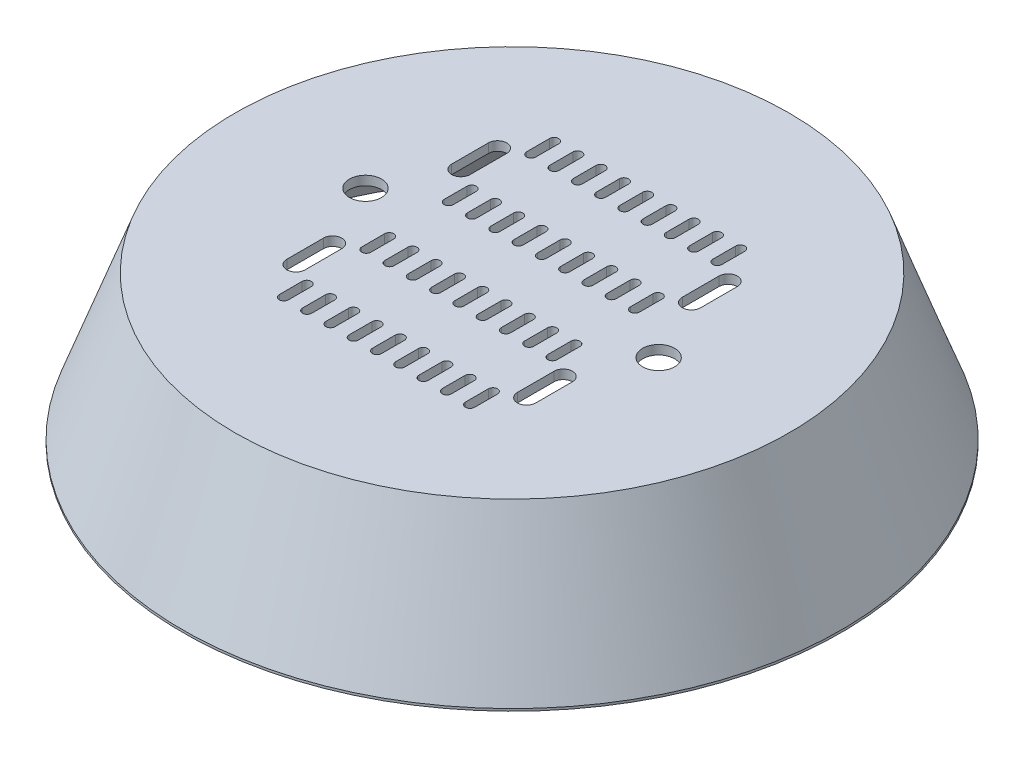
from build123d import *

# Parameters (mm, degrees)
CORTAR_EXTRUIR1_REACH   = 34
CROQUIS3_R              = 3.5
CORTAR_EXTRUIR2_DEPTH   = 2
CROQUIS5_R              = 7.5
CROQUIS5_R_2            = 3.5
SALIENTE_EXTRUIR1_DEPTH = 2
CORTAR_EXTRUIR3_REACH   = 34


with BuildPart() as part:
    # Croquis1 → Revolución1 (revolve)
    with BuildSketch(Plane.XY):
        Polygon((0, 0), (40, 0), (59.080892972, 0), (70, -30), (71.946370428, -30), (71.946370428, -29.5), (60.481308048, 2), (40, 2), (0, 2), align=None)
    revolve(axis=Axis((0, 0, 0), (0, 1, 0)))

    # Croquis3 → Cortar-Extruir1 (cut, up to next)
    with BuildSketch(Plane(origin=(0, 2, 0), x_dir=(1, 0, 0), z_dir=(0, 1, 0)), mode=Mode.PRIVATE) as cortar_extruir1_sk1:
        with Locations((-32, 0)):
            Circle(CROQUIS3_R)
    cortar_extruir1_tool1 = extrude(cortar_extruir1_sk1.sketch, amount=-CORTAR_EXTRUIR1_REACH, mode=Mode.PRIVATE) & part.part
    add(cortar_extruir1_tool1.solids().sort_by_distance((-32, 2, 0))[0], mode=Mode.SUBTRACT)
    # Croquis3 → Cortar-Extruir1 (cut, up to next)
    with BuildSketch(Plane(origin=(0, 2, 0), x_dir=(1, 0, 0), z_dir=(0, 1, 0)), mode=Mode.PRIVATE) as cortar_extruir1_sk2:
        with Locations((32, 0)):
            Circle(CROQUIS3_R)
    cortar_extruir1_tool2 = extrude(cortar_extruir1_sk2.sketch, amount=-CORTAR_EXTRUIR1_REACH, mode=Mode.PRIVATE) & part.part
    add(cortar_extruir1_tool2.solids().sort_by_distance((32, 2, 0))[0], mode=Mode.SUBTRACT)

    # Croquis4 → Cortar-Extruir2 (cut)
    with BuildSketch(Plane(origin=(0, 2, 0), x_dir=(1, 0, 0), z_dir=(0, 1, 0))):
        with BuildLine():
            Line((1, 11.5), (1, 6.5))
            ThreePointArc((1, 6.5), (0, 5.5), (-1, 6.5))
            Line((-1, 6.5), (-1, 11.5))
            ThreePointArc((-1, 11.5), (0, 12.5), (1, 11.5))
        make_face()
        with BuildLine():
            Line((6.08, 11.5), (6.08, 6.5))
            ThreePointArc((6.08, 6.5), (5.08, 5.5), (4.08, 6.5))
            Line((4.08, 6.5), (4.08, 11.5))
            ThreePointArc((4.08, 11.5), (5.08, 12.5), (6.08, 11.5))
        make_face()
        with BuildLine():
            Line((11.16, 11.5), (11.16, 6.5))
            ThreePointArc((11.16, 6.5), (10.16, 5.5), (9.16, 6.5))
            Line((9.16, 6.5), (9.16, 11.5))
            ThreePointArc((9.16, 11.5), (10.16, 12.5), (11.16, 11.5))
        make_face()
        with BuildLine():
            Line((16.24, 11.5), (16.24, 6.5))
            ThreePointArc((16.24, 6.5), (15.24, 5.5), (14.24, 6.5))
            Line((14.24, 6.5), (14.24, 11.5))
            ThreePointArc((14.24, 11.5), (15.24, 12.5), (16.24, 11.5))
        make_face()
        with BuildLine():
            Line((21.32, 11.5), (21.32, 6.5))
            ThreePointArc((21.32, 6.5), (20.32, 5.5), (19.32, 6.5))
            Line((19.32, 6.5), (19.32, 11.5))
            ThreePointArc((19.32, 11.5), (20.32, 12.5), (21.32, 11.5))
        make_face()
        with BuildLine():
            Line((-4.08, 11.5), (-4.08, 6.5))
            ThreePointArc((-4.08, 6.5), (-5.08, 5.5), (-6.08, 6.5))
            Line((-6.08, 6.5), (-6.08, 11.5))
            ThreePointArc((-6.08, 11.5), (-5.08, 12.5), (-4.08, 11.5))
        make_face()
        with BuildLine():
            Line((-9.16, 11.5), (-9.16, 6.5))
            ThreePointArc((-9.16, 6.5), (-10.16, 5.5), (-11.16, 6.5))
            Line((-11.16, 6.5), (-11.16, 11.5))
            ThreePointArc((-11.16, 11.5), (-10.16, 12.5), (-9.16, 11.5))
        make_face()
        with BuildLine():
            Line((-14.24, 11.5), (-14.24, 6.5))
            ThreePointArc((-14.24, 6.5), (-15.24, 5.5), (-16.24, 6.5))
            Line((-16.24, 6.5), (-16.24, 11.5))
            ThreePointArc((-16.24, 11.5), (-15.24, 12.5), (-14.24, 11.5))
        make_face()
        with BuildLine():
            Line((-19.32, 11.5), (-19.32, 6.5))
            ThreePointArc((-19.32, 6.5), (-20.32, 5.5), (-21.32, 6.5))
            Line((-21.32, 6.5), (-21.32, 11.5))
            ThreePointArc((-21.32, 11.5), (-20.32, 12.5), (-19.32, 11.5))
        make_face()
        with BuildLine():
            Line((1, 29.5), (1, 24.5))
            ThreePointArc((1, 24.5), (0, 23.5), (-1, 24.5))
            Line((-1, 24.5), (-1, 29.5))
            ThreePointArc((-1, 29.5), (0, 30.5), (1, 29.5))
        make_face()
        with BuildLine():
            Line((6.08, 29.5), (6.08, 24.5))
            ThreePointArc((6.08, 24.5), (5.08, 23.5), (4.08, 24.5))
            Line((4.08, 24.5), (4.08, 29.5))
            ThreePointArc((4.08, 29.5), (5.08, 30.5), (6.08, 29.5))
        make_face()
        with BuildLine():
            Line((11.16, 29.5), (11.16, 24.5))
            ThreePointArc((11.16, 24.5), (10.16, 23.5), (9.16, 24.5))
            Line((9.16, 24.5), (9.16, 29.5))
            ThreePointArc((9.16, 29.5), (10.16, 30.5), (11.16, 29.5))
        make_face()
        with BuildLine():
            Line((16.24, 29.5), (16.24, 24.5))
            ThreePointArc((16.24, 24.5), (15.24, 23.5), (14.24, 24.5))
            Line((14.24, 24.5), (14.24, 29.5))
            ThreePointArc((14.24, 29.5), (15.24, 30.5), (16.24, 29.5))
        make_face()
        with BuildLine():
            Line((21.32, 29.5), (21.32, 24.5))
            ThreePointArc((21.32, 24.5), (20.32, 23.5), (19.32, 24.5))
            Line((19.32, 24.5), (19.32, 29.5))
            ThreePointArc((19.32, 29.5), (20.32, 30.5), (21.32, 29.5))
        make_face()
        with BuildLine():
            Line((-4.08, 29.5), (-4.08, 24.5))
            ThreePointArc((-4.08, 24.5), (-5.08, 23.5), (-6.08, 24.5))
            Line((-6.08, 24.5), (-6.08, 29.5))
            ThreePointArc((-6.08, 29.5), (-5.08, 30.5), (-4.08, 29.5))
        make_face()
        with BuildLine():
            Line((-9.16, 29.5), (-9.16, 24.5))
            ThreePointArc((-9.16, 24.5), (-10.16, 23.5), (-11.16, 24.5))
            Line((-11.16, 24.5), (-11.16, 29.5))
            ThreePointArc((-11.16, 29.5), (-10.16, 30.5), (-9.16, 29.5))
        make_face()
        with BuildLine():
            Line((-14.24, 29.5), (-14.24, 24.5))
            ThreePointArc((-14.24, 24.5), (-15.24, 23.5), (-16.24, 24.5))
            Line((-16.24, 24.5), (-16.24, 29.5))
            ThreePointArc((-16.24, 29.5), (-15.24, 30.5), (-14.24, 29.5))
        make_face()
        with BuildLine():
            Line((-19.32, 29.5), (-19.32, 24.5))
            ThreePointArc((-19.32, 24.5), (-20.32, 23.5), (-21.32, 24.5))
            Line((-21.32, 24.5), (-21.32, 29.5))
            ThreePointArc((-21.32, 29.5), (-20.32, 30.5), (-19.32, 29.5))
        make_face()
        with BuildLine():
            Line((1, -6.5), (1, -11.5))
            ThreePointArc((1, -11.5), (0, -12.5), (-1, -11.5))
            Line((-1, -11.5), (-1, -6.5))
            ThreePointArc((-1, -6.5), (0, -5.5), (1, -6.5))
        make_face()
        with BuildLine():
            Line((6.08, -6.5), (6.08, -11.5))
            ThreePointArc((6.08, -11.5), (5.08, -12.5), (4.08, -11.5))
            Line((4.08, -11.5), (4.08, -6.5))
            ThreePointArc((4.08, -6.5), (5.08, -5.5), (6.08, -6.5))
        make_face()
        with BuildLine():
            Line((11.16, -6.5), (11.16, -11.5))
            ThreePointArc((11.16, -11.5), (10.16, -12.5), (9.16, -11.5))
            Line((9.16, -11.5), (9.16, -6.5))
            ThreePointArc((9.16, -6.5), (10.16, -5.5), (11.16, -6.5))
        make_face()
        with BuildLine():
            Line((16.24, -6.5), (16.24, -11.5))
            ThreePointArc((16.24, -11.5), (15.24, -12.5), (14.24, -11.5))
            Line((14.24, -11.5), (14.24, -6.5))
            ThreePointArc((14.24, -6.5), (15.24, -5.5), (16.24, -6.5))
        make_face()
        with BuildLine():
            Line((21.32, -6.5), (21.32, -11.5))
            ThreePointArc((21.32, -11.5), (20.32, -12.5), (19.32, -11.5))
            Line((19.32, -11.5), (19.32, -6.5))
            ThreePointArc((19.32, -6.5), (20.32, -5.5), (21.32, -6.5))
        make_face()
        with BuildLine():
            Line((-4.08, -6.5), (-4.08, -11.5))
            ThreePointArc((-4.08, -11.5), (-5.08, -12.5), (-6.08, -11.5))
            Line((-6.08, -11.5), (-6.08, -6.5))
            ThreePointArc((-6.08, -6.5), (-5.08, -5.5), (-4.08, -6.5))
        make_face()
        with BuildLine():
            Line((-9.16, -6.5), (-9.16, -11.5))
            ThreePointArc((-9.16, -11.5), (-10.16, -12.5), (-11.16, -11.5))
            Line((-11.16, -11.5), (-11.16, -6.5))
            ThreePointArc((-11.16, -6.5), (-10.16, -5.5), (-9.16, -6.5))
        make_face()
        with BuildLine():
            Line((-14.24, -6.5), (-14.24, -11.5))
            ThreePointArc((-14.24, -11.5), (-15.24, -12.5), (-16.24, -11.5))
            Line((-16.24, -11.5), (-16.24, -6.5))
            ThreePointArc((-16.24, -6.5), (-15.24, -5.5), (-14.24, -6.5))
        make_face()
        with BuildLine():
            Line((-19.32, -6.5), (-19.32, -11.5))
            ThreePointArc((-19.32, -11.5), (-20.32, -12.5), (-21.32, -11.5))
            Line((-21.32, -11.5), (-21.32, -6.5))
            ThreePointArc((-21.32, -6.5), (-20.32, -5.5), (-19.32, -6.5))
        make_face()
        with BuildLine():
            Line((1, -24.5), (1, -29.5))
            ThreePointArc((1, -29.5), (0, -30.5), (-1, -29.5))
            Line((-1, -29.5), (-1, -24.5))
            ThreePointArc((-1, -24.5), (0, -23.5), (1, -24.5))
        make_face()
        with BuildLine():
            Line((6.08, -24.5), (6.08, -29.5))
            ThreePointArc((6.08, -29.5), (5.08, -30.5), (4.08, -29.5))
            Line((4.08, -29.5), (4.08, -24.5))
            ThreePointArc((4.08, -24.5), (5.08, -23.5), (6.08, -24.5))
        make_face()
        with BuildLine():
            Line((11.16, -24.5), (11.16, -29.5))
            ThreePointArc((11.16, -29.5), (10.16, -30.5), (9.16, -29.5))
            Line((9.16, -29.5), (9.16, -24.5))
            ThreePointArc((9.16, -24.5), (10.16, -23.5), (11.16, -24.5))
        make_face()
        with BuildLine():
            Line((16.24, -24.5), (16.24, -29.5))
            ThreePointArc((16.24, -29.5), (15.24, -30.5), (14.24, -29.5))
            Line((14.24, -29.5), (14.24, -24.5))
            ThreePointArc((14.24, -24.5), (15.24, -23.5), (16.24, -24.5))
        make_face()
        with BuildLine():
            Line((21.32, -24.5), (21.32, -29.5))
            ThreePointArc((21.32, -29.5), (20.32, -30.5), (19.32, -29.5))
            Line((19.32, -29.5), (19.32, -24.5))
            ThreePointArc((19.32, -24.5), (20.32, -23.5), (21.32, -24.5))
        make_face()
        with BuildLine():
            Line((-4.08, -24.5), (-4.08, -29.5))
            ThreePointArc((-4.08, -29.5), (-5.08, -30.5), (-6.08, -29.5))
            Line((-6.08, -29.5), (-6.08, -24.5))
            ThreePointArc((-6.08, -24.5), (-5.08, -23.5), (-4.08, -24.5))
        make_face()
        with BuildLine():
            Line((-9.16, -24.5), (-9.16, -29.5))
            ThreePointArc((-9.16, -29.5), (-10.16, -30.5), (-11.16, -29.5))
            Line((-11.16, -29.5), (-11.16, -24.5))
            ThreePointArc((-11.16, -24.5), (-10.16, -23.5), (-9.16, -24.5))
        make_face()
        with BuildLine():
            Line((-14.24, -24.5), (-14.24, -29.5))
            ThreePointArc((-14.24, -29.5), (-15.24, -30.5), (-16.24, -29.5))
            Line((-16.24, -29.5), (-16.24, -24.5))
            ThreePointArc((-16.24, -24.5), (-15.24, -23.5), (-14.24, -24.5))
        make_face()
        with BuildLine():
            Line((-19.32, -24.5), (-19.32, -29.5))
            ThreePointArc((-19.32, -29.5), (-20.32, -30.5), (-21.32, -29.5))
            Line((-21.32, -29.5), (-21.32, -24.5))
            ThreePointArc((-21.32, -24.5), (-20.32, -23.5), (-19.32, -24.5))
        make_face()
    extrude(amount=-CORTAR_EXTRUIR2_DEPTH, mode=Mode.SUBTRACT)

    # Croquis5 → Saliente-Extruir1 (add)
    with BuildSketch(Plane(origin=(0, 0, 0), x_dir=(1, 0, 0), z_dir=(0, 1, 0))):
        with Locations((-32, 0)):
            Circle(CROQUIS5_R)
        with Locations((-32, 0)):
            Circle(CROQUIS5_R_2, mode=Mode.SUBTRACT)
        with Locations((32, 0)):
            Circle(CROQUIS5_R)
        with Locations((32, 0)):
            Circle(CROQUIS5_R_2, mode=Mode.SUBTRACT)
    extrude(amount=SALIENTE_EXTRUIR1_DEPTH)

    # Croquis12 → Cortar-Extruir3 (cut, up to next)
    with BuildSketch(Plane(origin=(0, 2, 0), x_dir=(1, 0, 0), z_dir=(0, 1, 0)), mode=Mode.PRIVATE) as cortar_extruir3_sk1:
        with BuildLine():
            Line((-23.170787181, 22), (-23.170787181, 14))
            ThreePointArc((-23.170787181, 14), (-25.170787181, 12), (-27.170787181, 14))
            Line((-27.170787181, 14), (-27.170787181, 22))
            ThreePointArc((-27.170787181, 22), (-25.170787181, 24), (-23.170787181, 22))
        make_face()
    cortar_extruir3_tool1 = extrude(cortar_extruir3_sk1.sketch, amount=-CORTAR_EXTRUIR3_REACH, mode=Mode.PRIVATE) & part.part
    add(cortar_extruir3_tool1.solids().sort_by_distance((-25.170787, 2, -18))[0], mode=Mode.SUBTRACT)
    # Croquis12 → Cortar-Extruir3 (cut, up to next)
    with BuildSketch(Plane(origin=(0, 2, 0), x_dir=(1, 0, 0), z_dir=(0, 1, 0)), mode=Mode.PRIVATE) as cortar_extruir3_sk2:
        with BuildLine():
            Line((23.170787181, 22), (23.170787181, 14))
            ThreePointArc((23.170787181, 14), (25.170787181, 12), (27.170787181, 14))
            Line((27.170787181, 14), (27.170787181, 22))
            ThreePointArc((27.170787181, 22), (25.170787181, 24), (23.170787181, 22))
        make_face()
    cortar_extruir3_tool2 = extrude(cortar_extruir3_sk2.sketch, amount=-CORTAR_EXTRUIR3_REACH, mode=Mode.PRIVATE) & part.part
    add(cortar_extruir3_tool2.solids().sort_by_distance((25.170787, 2, -18))[0], mode=Mode.SUBTRACT)
    # Croquis12 → Cortar-Extruir3 (cut, up to next)
    with BuildSketch(Plane(origin=(0, 2, 0), x_dir=(1, 0, 0), z_dir=(0, 1, 0)), mode=Mode.PRIVATE) as cortar_extruir3_sk3:
        with BuildLine():
            Line((-23.170787181, -22), (-23.170787181, -14))
            ThreePointArc((-23.170787181, -14), (-25.170787181, -12), (-27.170787181, -14))
            Line((-27.170787181, -14), (-27.170787181, -22))
            ThreePointArc((-27.170787181, -22), (-25.170787181, -24), (-23.170787181, -22))
        make_face()
    cortar_extruir3_tool3 = extrude(cortar_extruir3_sk3.sketch, amount=-CORTAR_EXTRUIR3_REACH, mode=Mode.PRIVATE) & part.part
    add(cortar_extruir3_tool3.solids().sort_by_distance((-25.170787, 2, 18))[0], mode=Mode.SUBTRACT)
    # Croquis12 → Cortar-Extruir3 (cut, up to next)
    with BuildSketch(Plane(origin=(0, 2, 0), x_dir=(1, 0, 0), z_dir=(0, 1, 0)), mode=Mode.PRIVATE) as cortar_extruir3_sk4:
        with BuildLine():
            Line((23.170787181, -22), (23.170787181, -14))
            ThreePointArc((23.170787181, -14), (25.170787181, -12), (27.170787181, -14))
            Line((27.170787181, -14), (27.170787181, -22))
            ThreePointArc((27.170787181, -22), (25.170787181, -24), (23.170787181, -22))
        make_face()
    cortar_extruir3_tool4 = extrude(cortar_extruir3_sk4.sketch, amount=-CORTAR_EXTRUIR3_REACH, mode=Mode.PRIVATE) & part.part
    add(cortar_extruir3_tool4.solids().sort_by_distance((25.170787, 2, 18))[0], mode=Mode.SUBTRACT)


solid = part.part
